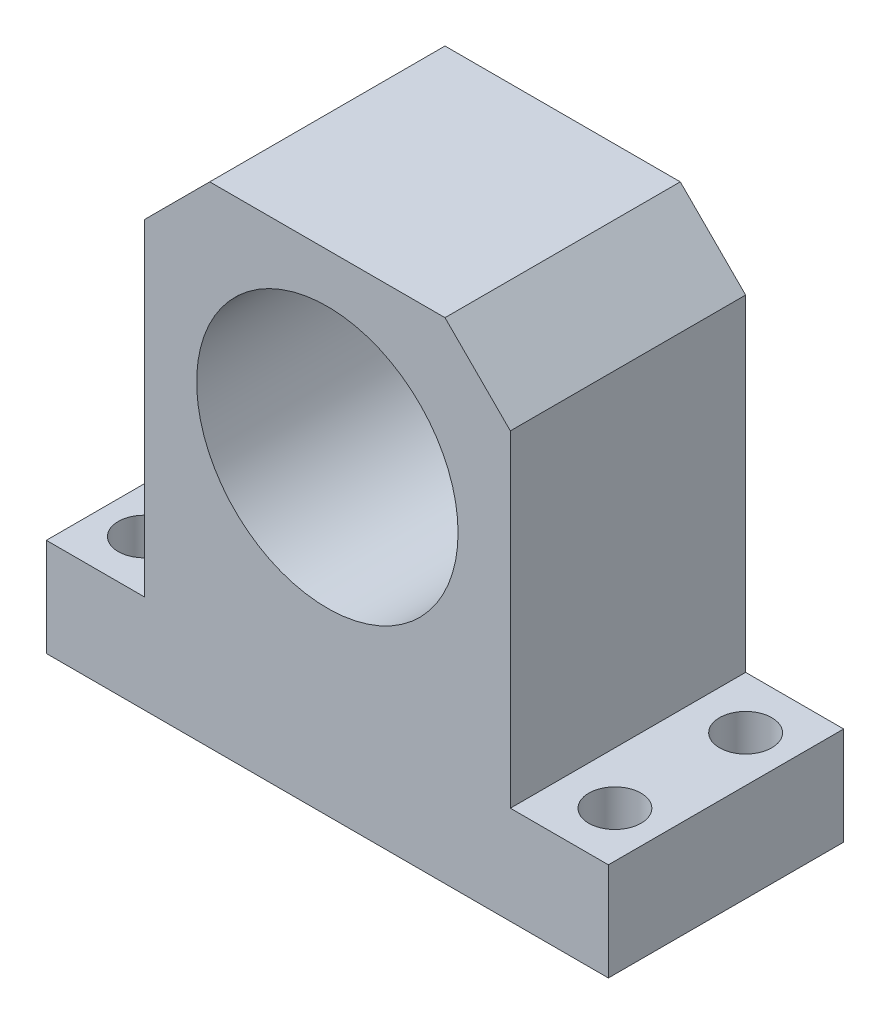
from build123d import *

# Parameters (mm, degrees)
DODANIE_WYCI_GNI_CIE1_DEPTH = 36
SZKIC2_R                    = 20
WYTNIJ_WYCI_GNI_CIE1_DEPTH  = 36
SFAZOWANIE1_SIZE            = 10
SZKIC3_R                    = 4
WYTNIJ_WYCI_GNI_CIE2_DEPTH  = 18


with BuildPart() as part:
    # Szkic1 → Dodanie-wyciągnięcie1 (new body)
    with BuildSketch(Plane.XY):
        Polygon((0, 0), (86, 0), (86, 15), (71, 15), (71, 75), (15, 75), (15, 15), (0, 15), align=None)
    extrude(amount=DODANIE_WYCI_GNI_CIE1_DEPTH)

    # Szkic2 → Wytnij-wyciągnięcie1 (cut)
    with BuildSketch(Plane.XY.offset(36)):
        with Locations((43, 47.5)):
            Circle(SZKIC2_R)
    extrude(amount=-WYTNIJ_WYCI_GNI_CIE1_DEPTH, mode=Mode.SUBTRACT)

    # Sfazowanie1
    sfazowanie1_edges = [part.edges().sort_by_distance(p)[0] for p in [
        (15, 75, 18),
        (71, 75, 18),
    ]]
    chamfer(sfazowanie1_edges, length=SFAZOWANIE1_SIZE)

    # Szkic3 → Wytnij-wyciągnięcie2 (cut)
    with BuildSketch(Plane(origin=(0, 15, 0), x_dir=(1, 0, 0), z_dir=(0, 1, 0))):
        with Locations((79, -8)):
            Circle(SZKIC3_R)
        with Locations((7, -8)):
            Circle(SZKIC3_R)
        with Locations((79, -28)):
            Circle(SZKIC3_R)
        with Locations((7, -28)):
            Circle(SZKIC3_R)
    extrude(amount=-WYTNIJ_WYCI_GNI_CIE2_DEPTH, mode=Mode.SUBTRACT)


solid = part.part
